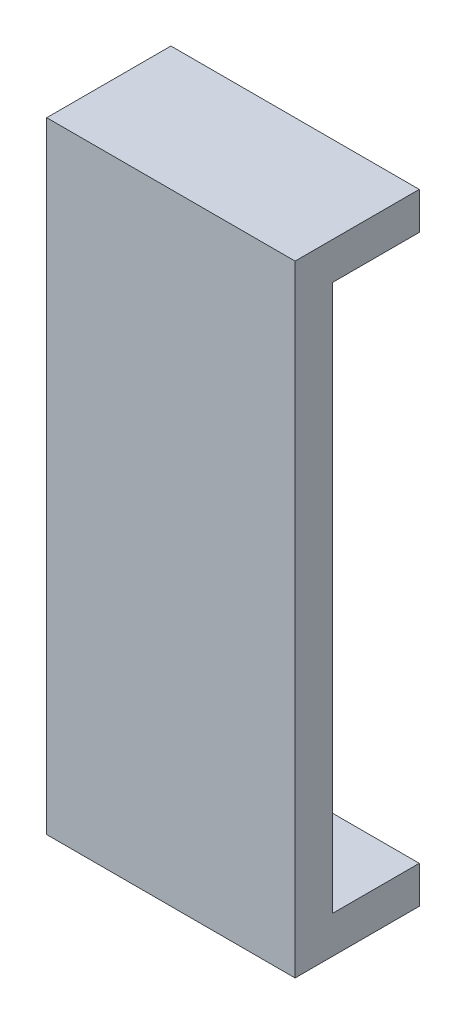
from build123d import *

# Parameters (mm, degrees)
CROQUIS1_W              = 20
CROQUIS1_H              = 50
SALIENTE_EXTRUIR1_DEPTH = 3
CROQUIS2_W              = 20
CROQUIS2_H              = 3
SALIENTE_EXTRUIR2_DEPTH = 7
CROQUIS3_W              = 20
CROQUIS3_H              = 3
SALIENTE_EXTRUIR3_DEPTH = 7


with BuildPart() as part:
    # Croquis1 → Saliente-Extruir1 (new body)
    with BuildSketch(Plane.XY):
        Rectangle(CROQUIS1_W, CROQUIS1_H)
    extrude(amount=SALIENTE_EXTRUIR1_DEPTH)

    # Croquis2 → Saliente-Extruir2 (add)
    with BuildSketch(Plane(origin=(0, 0, 0), x_dir=(-1, 0, 0), z_dir=(0, 0, -1))):
        with Locations((0, 23.5)):
            Rectangle(CROQUIS2_W, CROQUIS2_H)
    extrude(amount=SALIENTE_EXTRUIR2_DEPTH)

    # Croquis3 → Saliente-Extruir3 (add)
    with BuildSketch(Plane(origin=(0, 0, 0), x_dir=(-1, 0, 0), z_dir=(0, 0, -1))):
        with Locations((0, -23.5)):
            Rectangle(CROQUIS3_W, CROQUIS3_H)
    extrude(amount=SALIENTE_EXTRUIR3_DEPTH)


solid = part.part
